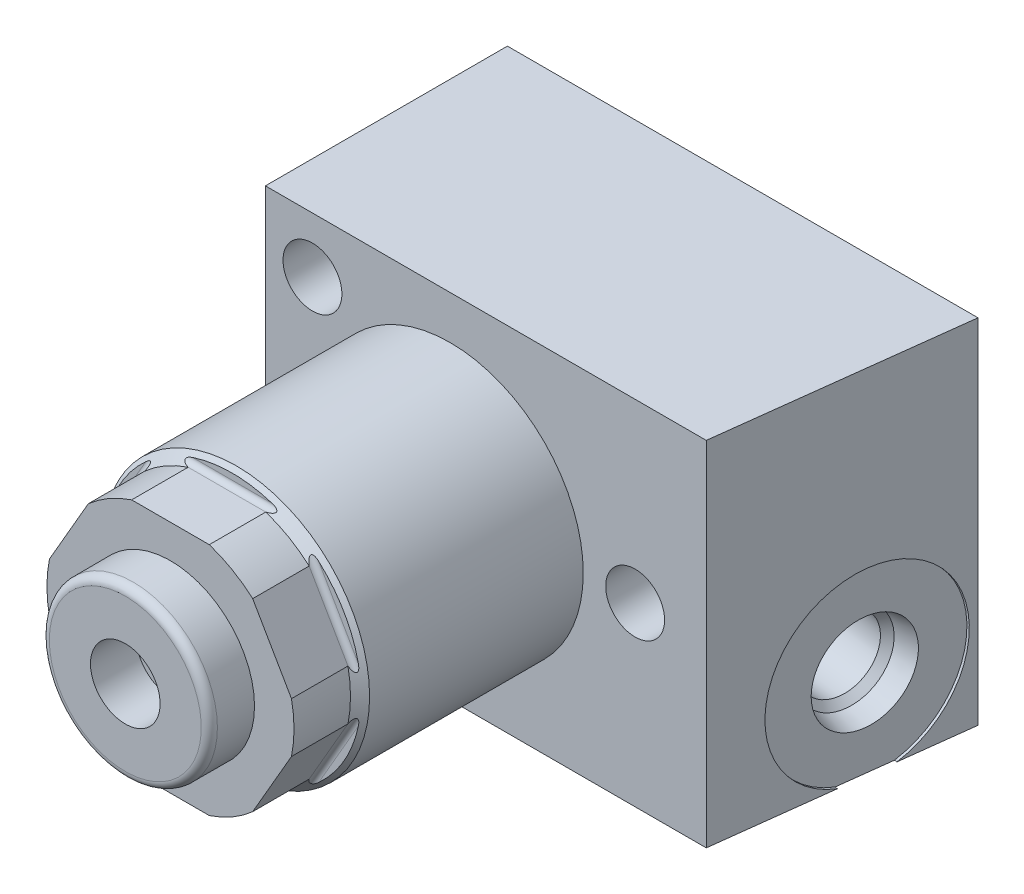
from build123d import *

# Parameters (mm, degrees)
SKETCH1_R           = 12.573
EXTRUDE1_DEPTH      = 40.005
CUT_EXTRUDE1_DEPTH  = 15.0876
SKETCH11_W          = 4.2672
SKETCH11_H          = 7.9375
S2D0011_W           = 3.2893
S2D0011_H           = 4.318
FILLET1_R           = 0.762
EXTRUDE2_DEPTH      = 16.66875
EXTRUDE2_DEPTH_BACK = 16.66875
SKETCH14_R          = 8.6614
CUT_EXTRUDE9_DEPTH  = 0.254
SKETCH17_R          = 1.2065
CIRPATTERN2_COUNT   = 6
SKETCH18_W          = 2.7813
SKETCH18_H          = 22.86
HOLE1_AT_2_COUNT    = 2
HOLE1_AT_2_PITCH    = 32.55265427
HOLE1_AT_3_COUNT    = 2
HOLE1_AT_3_PITCH    = 22.86


with BuildPart() as part:
    # Sketch1 → Extrude1 (new body)
    with BuildSketch(Plane.XY):
        Circle(SKETCH1_R)
    extrude(amount=EXTRUDE1_DEPTH)

    # Sketch2 → Cut-Extrude1 (cut, symmetric)
    with BuildSketch(Plane(origin=(0, 0, 0), x_dir=(0, 0, 1), z_dir=(1, 0, 0))):
        with BuildLine():
            Line((34.163, 12.573), (34.163, 11.58875))
            ThreePointArc((34.163, 11.58875), (34.311789755, 11.229539755), (34.671, 11.08075))
            Line((34.671, 11.08075), (40.005, 11.08075))
            Line((40.005, 11.08075), (40.005, 12.573))
            Line((40.005, 12.573), (34.163, 12.573))
        make_face()
    cut_extrude1 = extrude(amount=CUT_EXTRUDE1_DEPTH, both=True, mode=Mode.SUBTRACT)

    # Sketch10 → Cut-Revolve1 (revolve, cut)
    with BuildSketch(Plane(origin=(0, 0, 0), x_dir=(0, 0, -1), z_dir=(1, 0, 0)), mode=Mode.PRIVATE) as cut_revolve1_sk:
        Polygon((-40.005, 11.6713), (-34.671, 11.6713), (-33.7693, 12.573), (-40.005, 12.573), align=None)
    revolve(cut_revolve1_sk.sketch.rotate(Axis((0, 0, 40.316785), (0, 0, -1)), 90), axis=Axis((0, 0, 40.316785), (0, 0, -1)), mode=Mode.SUBTRACT)  # turned: the seam where the file's is

    # Sketch11 → Revolve1 (revolve)
    with BuildSketch(Plane(origin=(0, 0, 0), x_dir=(0, 0, -1), z_dir=(1, 0, 0)), mode=Mode.PRIVATE) as revolve1_sk:
        with Locations((-42.1386, 3.96875)):
            Rectangle(SKETCH11_W, SKETCH11_H)
    revolve(revolve1_sk.sketch.rotate(Axis((0, 0, 44.48556), (0, 0, -1)), 90), axis=Axis((0, 0, 44.48556), (0, 0, -1)))  # turned: the seam where the file's is

    # S2D0011 → Cut-Revolve2 (revolve, cut)
    with BuildSketch(Plane(origin=(-3.2893, 0, 44.2722), x_dir=(-1, 0, 0), z_dir=(0, 1, 0)), mode=Mode.PRIVATE) as cut_revolve2_sk:
        with Locations((-1.64465, -2.159)):
            Rectangle(S2D0011_W, S2D0011_H)
    revolve(cut_revolve2_sk.sketch.rotate(Axis((0, 0, 28.856062964), (0, 0, 1)), 180), axis=Axis((0, 0, 28.856062964), (0, 0, 1)), mode=Mode.SUBTRACT)  # turned: the seam where the file's is

    # Fillet1
    fillet1_edges = [part.edges().sort_by_distance(p)[0] for p in [
        (-7.9375, 0, 44.2722),
    ]]
    fillet(fillet1_edges, radius=FILLET1_R)

    # Sketch13 → Extrude2 (add, two sides)
    with BuildSketch(Plane(origin=(0, 0, 0), x_dir=(-1, 0, 0), z_dir=(0, 1, 0))) as extrude2_sk:
        Polygon((-27.0002, -9.271), (17.4498, -9.271), (17.4498, 13.589), (-24.193344938, 13.589), align=None)
    extrude(amount=EXTRUDE2_DEPTH)
    extrude(extrude2_sk.sketch, amount=-EXTRUDE2_DEPTH_BACK)

    # Sketch14 → Cut-Extrude9 (cut)
    with BuildSketch(Plane(origin=(25.477760387, 0, 3.128275622), x_dir=(0.121869343, 0, -0.992546152), z_dir=(0.992546152, 0, 0.121869343))):
        with Locations((3.094392018, -8.382)):
            Circle(SKETCH14_R)
    extrude(amount=-CUT_EXTRUDE9_DEPTH, mode=Mode.SUBTRACT)

    # S2D0002 → Cut-Revolve3 (revolve, cut)
    with BuildSketch(Plane(origin=(25.602765188, -8.382, 0.02599392), x_dir=(-0.121869343, 0, 0.992546152), z_dir=(0, 1, 0))):
        Polygon((0, 0), (4.5466, 0), (4.106586662, -2.0701), (3.4544, -2.722286662), (3.4544, -12.192), (0, -12.192), align=None)
    revolve(axis=Axis((12.896586373, -8.382, -1.534128667), (0.992546152, 0, 0.121869343)), mode=Mode.SUBTRACT)

    # Sketch16 → Cut-Revolve4 (revolve, cut)
    with BuildSketch(Plane(origin=(17.4752, 9.72185, -8.345048891), x_dir=(-1, 0, 0), z_dir=(0, 1, 0))):
        Polygon((0, -0.925951109), (6.35, -0.925951109), (6.35, 1.487048891), (2.3876, 1.487048891), (2.3876, 11.012048891), (0, 12.446663705), align=None)
    revolve(axis=Axis((17.4752, 9.72185, -9.939630741), (0, 0, 1)), mode=Mode.SUBTRACT)

    # CirPattern2: Cut-Extrude1 ×6 about axis
    cirpattern2_axis = Axis((0, 0, 0), (0, 0, 1))
    for i in range(1, CIRPATTERN2_COUNT):
        add(cut_extrude1.rotate(cirpattern2_axis, i * 360 / CIRPATTERN2_COUNT), mode=Mode.SUBTRACT)

    # Sketch18 → Hole1 (revolve, cut)
    with BuildSketch(Plane(origin=(-13.0048, -11.43, 13.589), x_dir=(0, -1, 0), z_dir=(1, 0, 0))):
        with Locations((1.39065, 11.43)):
            Rectangle(SKETCH18_W, SKETCH18_H)
    hole1 = revolve(axis=Axis((-13.0048, -11.43, -96.411), (0, 0, 1)), mode=Mode.SUBTRACT)

    # Hole1 at 2: Hole1 ×2
    with Locations(*[Vector(0.936329178, 0.351123442, 0) * (i * HOLE1_AT_2_PITCH) for i in range(1, HOLE1_AT_2_COUNT)]):
        add(hole1, mode=Mode.SUBTRACT)

    # Hole1 at 3: Hole1 ×2
    with Locations(*[(0, i * HOLE1_AT_3_PITCH, 0) for i in range(1, HOLE1_AT_3_COUNT)]):
        add(hole1, mode=Mode.SUBTRACT)


with BuildPart() as body_2:
    # Sketch17 → Revolve2 (revolve)
    with BuildSketch(Plane(origin=(17.4752, 9.72185, -8.345048891), x_dir=(-1, 0, 0), z_dir=(0, 1, 0)), mode=Mode.PRIVATE) as revolve2_sk:
        with Locations((-5.1435, 0.280548891)):
            Circle(SKETCH17_R)
    revolve(revolve2_sk.sketch.rotate(Axis((17.4752, 9.72185, -9.39165), (0, 0, 1)), 180), axis=Axis((17.4752, 9.72185, -9.39165), (0, 0, 1)))  # turned: the seam where the file's is


solid = Compound([part.part, body_2.part])
